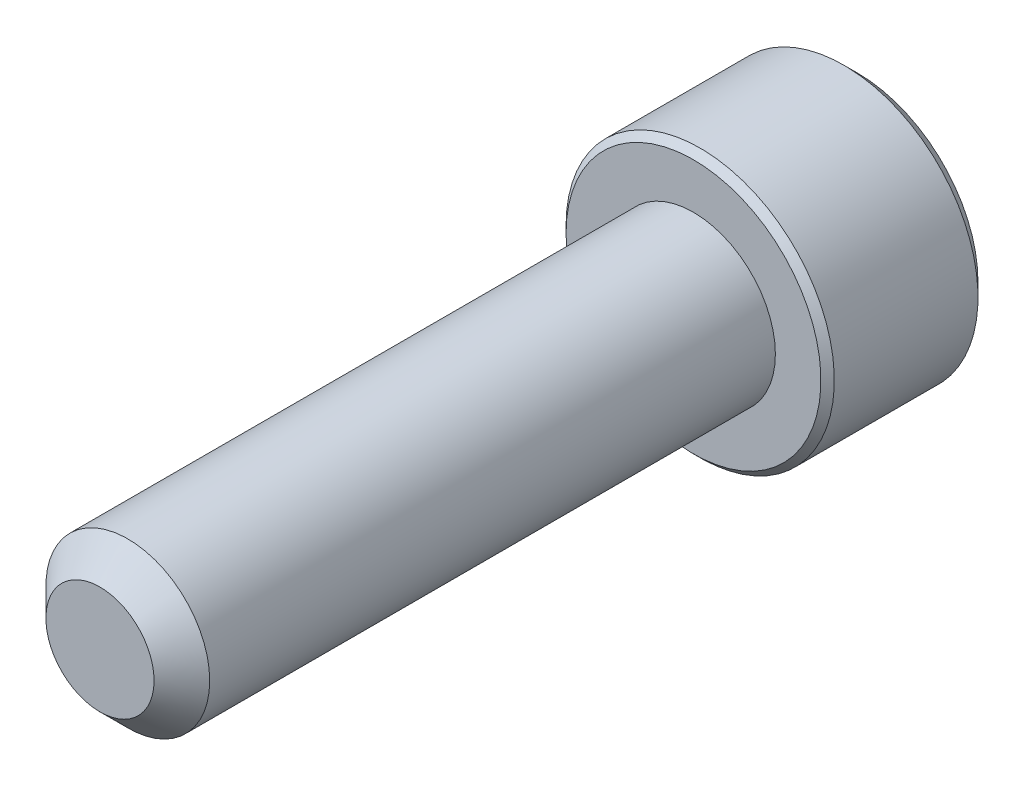
from build123d import *

# Parameters (mm, degrees)
SKETCH1_R          = 1.7526
EXTRUDE1_DEPTH     = 12.7
CHAMFER3_SIZE      = 0.5953125
SKETCH6_R          = 2.8702
EXTRUDE2_DEPTH     = 3.5052
CUT_EXTRUDE1_DEPTH = 2.08359375
CHAMFER1_SIZE      = 0.28702
CHAMFER2_SIZE      = 0.14351


with BuildPart() as part:
    # Sketch1 → Extrude1 (new body)
    with BuildSketch(Plane.XY):
        Circle(SKETCH1_R)
    extrude(amount=-EXTRUDE1_DEPTH)

    # Chamfer3
    chamfer3_edges = [part.edges().sort_by_distance(p)[0] for p in [
        (-1.7526, 0, 0),
    ]]
    chamfer(chamfer3_edges, length=CHAMFER3_SIZE)

    # Sketch6 → Extrude2 (add)
    with BuildSketch(Plane(origin=(0, 0, -12.7), x_dir=(-1, 0, 0), z_dir=(0, 0, -1))):
        Circle(SKETCH6_R)
    extrude(amount=EXTRUDE2_DEPTH)

    # Sketch7 → Cut-Extrude1 (cut)
    with BuildSketch(Plane(origin=(0, 0, -16.2052), x_dir=(-1, 0, 0), z_dir=(0, 0, -1))):
        Polygon((0, 1.603951217), (-1.3890625, 0.801975608), (-1.3890625, -0.801975608), (0, -1.603951217), (1.3890625, -0.801975608), (1.3890625, 0.801975608), align=None)
    extrude(amount=-CUT_EXTRUDE1_DEPTH, mode=Mode.SUBTRACT)

    # Cut-Extrude2 cone 1 section (through the dimple's axis) → Cut-Extrude2 (revolve, cut)
    with BuildSketch(Plane(origin=(0, 0, -16.2052), x_dir=(0, 1, 0), z_dir=(1, 0, 0))):
        Polygon((0, 0), (1.603951217, 0), (0, 1.603951217), align=None)
    revolve(axis=Axis((0, 0, -16.2052), (0, 0, 1)), mode=Mode.SUBTRACT)

    # Chamfer1
    chamfer1_edges = [part.edges().sort_by_distance(p)[0] for p in [
        (2.8702, 0, -16.2052),
    ]]
    chamfer(chamfer1_edges, length=CHAMFER1_SIZE)

    # Chamfer2
    chamfer2_edges = [part.edges().sort_by_distance(p)[0] for p in [
        (2.8702, 0, -12.7),
    ]]
    chamfer(chamfer2_edges, length=CHAMFER2_SIZE)


solid = part.part
